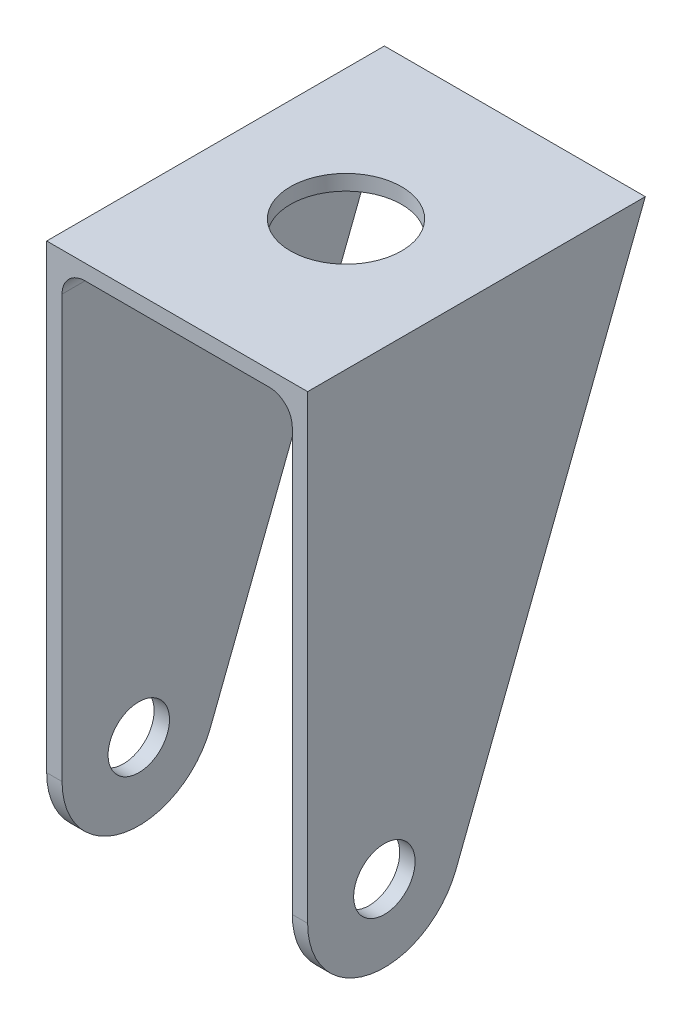
from build123d import *

# Parameters (mm, degrees)
CROQUIS1_R                        = 4
SALIENTE_EXTRUIR1_DEPTH           = 34
CORTAR_EXTRUIR1_REACH             = 36
CORTAR_EXTRUIR1_DIRECTION_2_REACH = 12
CORTAR_EXTRUIR2_REACH             = 72
CROQUIS4_R                        = 7.25


with BuildPart() as part:
    # Croquis1 → Saliente-Extruir1 (new body)
    with BuildSketch(Plane(origin=(17, 0, 0), x_dir=(0, 0, -1), z_dir=(1, 0, 0))):
        with BuildLine():
            Line((-10, 0), (-10, 60))
            Line((-10, 60), (34, 60))
            Line((34, 60), (9.323156657, -3.616455439))
            ThreePointArc((9.323156657, -3.616455439), (-1.839624069, -9.8293328), (-10, 0))
        make_face()
        Circle(CROQUIS1_R, mode=Mode.SUBTRACT)
    extrude(amount=-SALIENTE_EXTRUIR1_DEPTH)

    # Croquis3 → Cortar-Extruir1 (cut, up to next)
    with BuildSketch(Plane.XY, mode=Mode.PRIVATE) as cortar_extruir1_sk1:
        with BuildLine():
            Line((-15, -10), (15, -10))
            Line((15, -10), (15, 55))
            ThreePointArc((15, 55), (14.121320344, 57.121320344), (12, 58))
            Line((12, 58), (-12, 58))
            ThreePointArc((-12, 58), (-14.121320344, 57.121320344), (-15, 55))
            Line((-15, 55), (-15, -10))
        make_face()
    cortar_extruir1_tool1 = extrude(cortar_extruir1_sk1.sketch, amount=-CORTAR_EXTRUIR1_REACH, mode=Mode.PRIVATE) & part.part
    add(cortar_extruir1_tool1.solids().sort_by_distance((0, 23.936769, 0))[0], mode=Mode.SUBTRACT)

    # Croquis3 → Cortar-Extruir1 direction 2 (cut, up to next)
    with BuildSketch(Plane.XY, mode=Mode.PRIVATE) as cortar_extruir1_direction_2_sk1:
        with BuildLine():
            Line((-15, -10), (15, -10))
            Line((15, -10), (15, 55))
            ThreePointArc((15, 55), (14.121320344, 57.121320344), (12, 58))
            Line((12, 58), (-12, 58))
            ThreePointArc((-12, 58), (-14.121320344, 57.121320344), (-15, 55))
            Line((-15, 55), (-15, -10))
        make_face()
    cortar_extruir1_direction_2_tool1 = extrude(cortar_extruir1_direction_2_sk1.sketch, amount=CORTAR_EXTRUIR1_DIRECTION_2_REACH, mode=Mode.PRIVATE) & part.part
    add(cortar_extruir1_direction_2_tool1.solids().sort_by_distance((0, 23.936769, 0))[0], mode=Mode.SUBTRACT)

    # Croquis4 → Cortar-Extruir2 (cut, up to next)
    with BuildSketch(Plane(origin=(0, 60, 0), x_dir=(1, 0, 0), z_dir=(0, 1, 0)), mode=Mode.PRIVATE) as cortar_extruir2_sk1:
        with Locations((0, 12)):
            Circle(CROQUIS4_R)
    cortar_extruir2_tool1 = extrude(cortar_extruir2_sk1.sketch, amount=-CORTAR_EXTRUIR2_REACH, mode=Mode.PRIVATE) & part.part
    add(cortar_extruir2_tool1.solids().sort_by_distance((0, 60, -12))[0], mode=Mode.SUBTRACT)


solid = part.part
